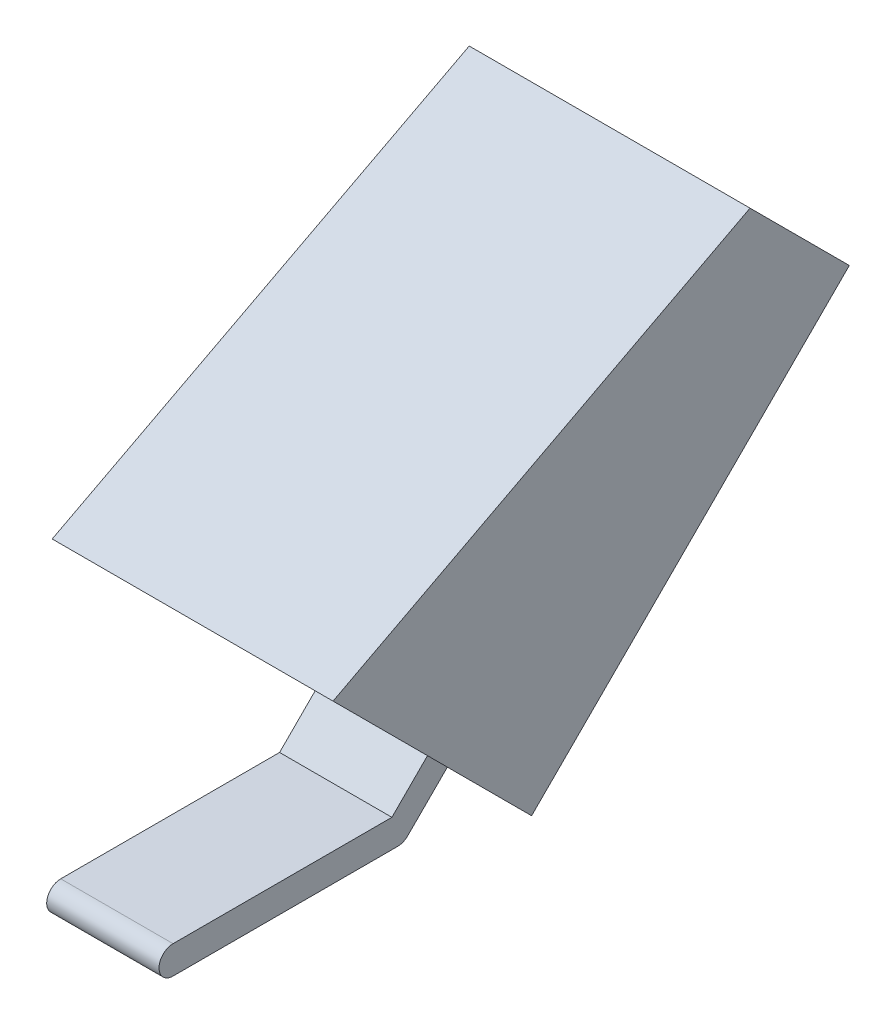
from build123d import *

# Parameters (mm, degrees)
EXTRUDE_2_DEPTH     = 4
SKETCH_5_W          = 20
SKETCH_5_H          = 32
EXTRUDE_5_DEPTH     = 20
CUT_EXTRUDE_3_DEPTH = 20


with BuildPart() as part:
    # 草图1 → 凸台-拉伸2 (new body, symmetric)
    with BuildSketch(Plane(origin=(0, 0, 0), x_dir=(0, 0, -1), z_dir=(1, 0, 0))):
        with BuildLine():
            Line((-8, 1), (7.585786438, 1))
            Line((7.585786438, 1), (27.091883092, 20.506096654))
            ThreePointArc((27.091883092, 20.506096654), (28.506096654, 20.506096654), (28.506096654, 19.091883092))
            Line((28.506096654, 19.091883092), (8.707106781, -0.707106781))
            ThreePointArc((8.707106781, -0.707106781), (8.382683432, -0.923879533), (8, -1))
            Line((8, -1), (-8, -1))
            ThreePointArc((-8, -1), (-9, 0), (-8, 1))
        make_face()
    extrude(amount=EXTRUDE_2_DEPTH, both=True)

    # 草图5 → 凸台-拉伸5 (add)
    with BuildSketch(Plane(origin=(0, -4.707106781, -4.707106781), x_dir=(1, 0, 0), z_dir=(0, -0.707106781, -0.707106781))):
        with Locations((0, -25.656854249)):
            Rectangle(SKETCH_5_W, SKETCH_5_H)
    extrude(amount=-EXTRUDE_5_DEPTH)

    # 草图6 → 切除-拉伸3 (cut)
    with BuildSketch(Plane.ZY.offset(10)):
        Polygon((2.606601718, 16.263455967), (-27.091883092, 31.819805153), (-20.02081528, 38.890872965), align=None)
    extrude(amount=-CUT_EXTRUDE_3_DEPTH, mode=Mode.SUBTRACT)


solid = part.part
